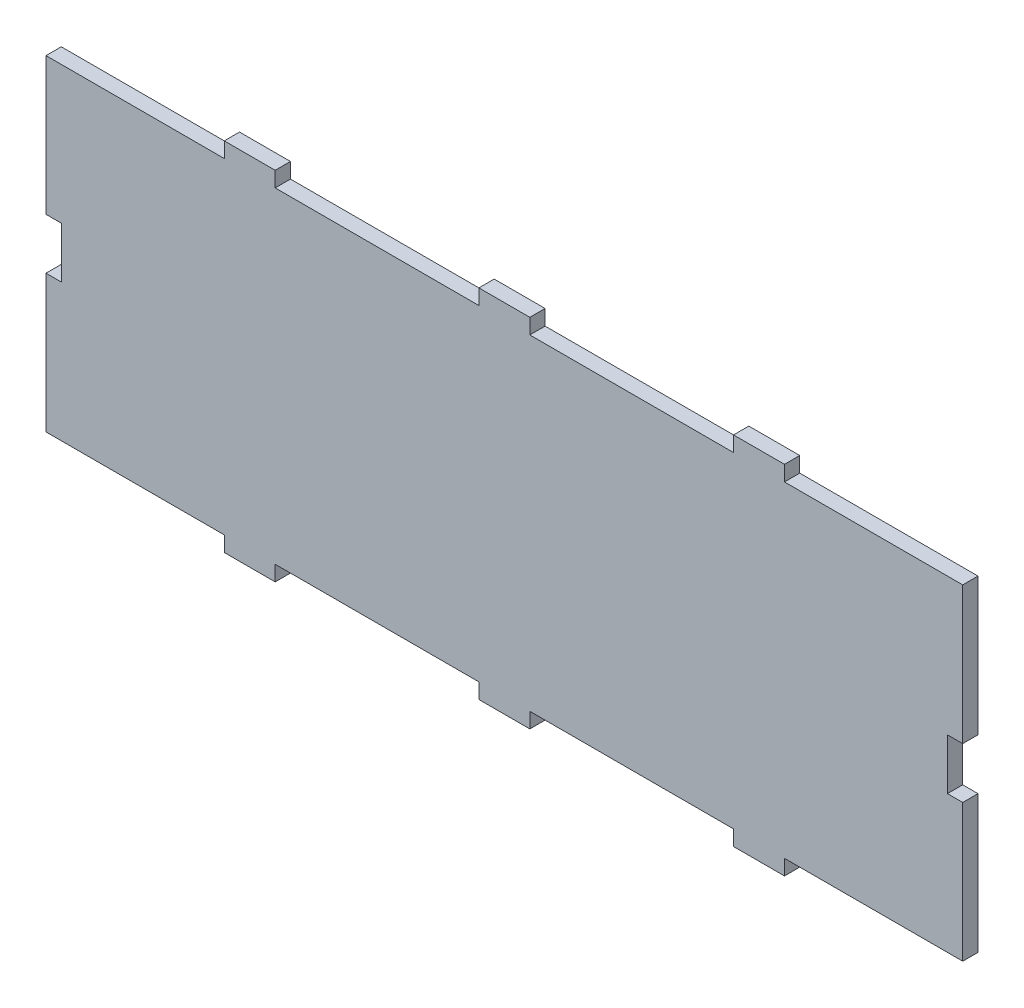
from build123d import *

# Parameters (mm, degrees)
SKETCH3_W           = 180
SKETCH3_H           = 70
BOSS_EXTRUDE1_DEPTH = 3
SKETCH5_W           = 3
SKETCH5_H           = 5
CUT_EXTRUDE2_DEPTH  = 3
SKETCH4_W           = 35
SKETCH4_H           = 3
SKETCH4_W_2         = 40
CUT_EXTRUDE3_DEPTH  = 10


with BuildPart() as part:
    # Sketch3 → Boss-Extrude1 (new body)
    with BuildSketch(Plane.XY):
        Rectangle(SKETCH3_W, SKETCH3_H)
    extrude(amount=BOSS_EXTRUDE1_DEPTH)

    # Sketch5 → Cut-Extrude2 (cut)
    with BuildSketch(Plane.XY.offset(3)):
        with Locations((-88.5, 2.5)):
            Rectangle(SKETCH5_W, SKETCH5_H)
        with Locations((-88.5, -2.5)):
            Rectangle(SKETCH5_W, SKETCH5_H)
        with Locations((88.5, 2.5)):
            Rectangle(SKETCH5_W, SKETCH5_H)
        with Locations((88.5, -2.5)):
            Rectangle(SKETCH5_W, SKETCH5_H)
    extrude(amount=-CUT_EXTRUDE2_DEPTH, mode=Mode.SUBTRACT)

    # Sketch4 → Cut-Extrude3 (cut)
    with BuildSketch(Plane.XY.offset(3)):
        with Locations((-72.5, 33.5)):
            Rectangle(SKETCH4_W, SKETCH4_H)
        with Locations((-25, 33.5)):
            Rectangle(SKETCH4_W_2, SKETCH4_H)
        with Locations((25, 33.5)):
            Rectangle(SKETCH4_W_2, SKETCH4_H)
        with Locations((72.5, 33.5)):
            Rectangle(SKETCH4_W, SKETCH4_H)
        with Locations((72.5, -33.5)):
            Rectangle(SKETCH4_W, SKETCH4_H)
        with Locations((25, -33.5)):
            Rectangle(SKETCH4_W_2, SKETCH4_H)
        with Locations((-25, -33.5)):
            Rectangle(SKETCH4_W_2, SKETCH4_H)
        with Locations((-72.5, -33.5)):
            Rectangle(SKETCH4_W, SKETCH4_H)
    extrude(amount=-CUT_EXTRUDE3_DEPTH, mode=Mode.SUBTRACT)


solid = part.part
